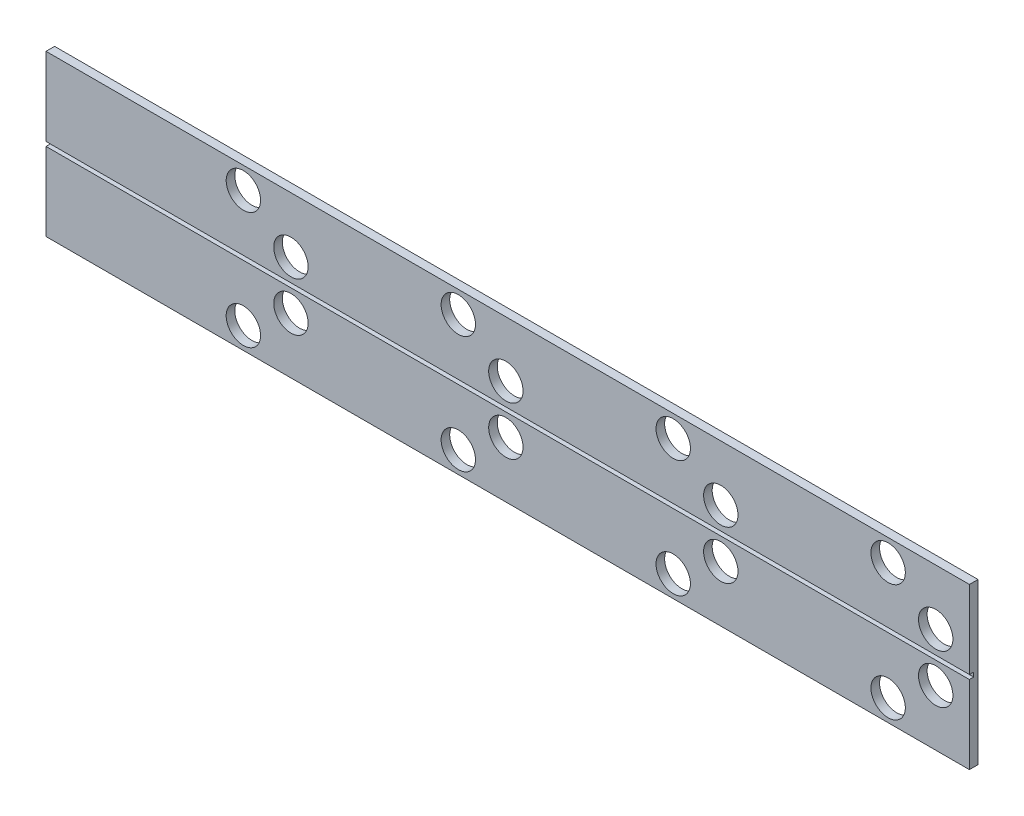
from build123d import *

# Parameters (mm, degrees)
SKIZZE1_W                       = 21.482125196
SKIZZE1_H                       = 3.731950896
AUFSATZ_LINEAR_AUSTRAGEN1_DEPTH = 0.2
SKIZZE2_W                       = 21.482125196
SKIZZE2_H                       = 0.1
SCHNITT_LINEAR_AUSTRAGEN1_DEPTH = 0.1
SKIZZE3_R                       = 0.4
SCHNITT_LINEAR_AUSTRAGEN2_DEPTH = 1.2
LINEARES_MUSTER1_COUNT          = 4
LINEARES_MUSTER1_PITCH          = 5


with BuildPart() as part:
    # Skizze1 → Aufsatz-Linear austragen1 (new body)
    with BuildSketch(Plane.XY):
        Rectangle(SKIZZE1_W, SKIZZE1_H)
    extrude(amount=AUFSATZ_LINEAR_AUSTRAGEN1_DEPTH)

    # Skizze2 → Schnitt-Linear austragen1 (cut)
    with BuildSketch(Plane.XY.offset(0.2)):
        Rectangle(SKIZZE2_W, SKIZZE2_H)
    extrude(amount=-SCHNITT_LINEAR_AUSTRAGEN1_DEPTH, mode=Mode.SUBTRACT)

    # Skizze3 → Schnitt-Linear austragen2 (cut, through all)
    with BuildSketch(Plane.XY.offset(0.2)):
        with Locations((9.957181888, -0.562943668)):
            Circle(SKIZZE3_R)
        with Locations((8.850641756, -1.365185264)):
            Circle(SKIZZE3_R)
        with Locations((9.957181888, 0.571259967)):
            Circle(SKIZZE3_R)
        with Locations((8.850641756, 1.359669812)):
            Circle(SKIZZE3_R)
    schnitt_linear_austragen2 = extrude(amount=-SCHNITT_LINEAR_AUSTRAGEN2_DEPTH, mode=Mode.SUBTRACT)

    # Lineares Muster1: Schnitt-Linear austragen2 ×4
    with Locations(*[(-i * LINEARES_MUSTER1_PITCH, 0, 0) for i in range(1, LINEARES_MUSTER1_COUNT)]):
        add(schnitt_linear_austragen2, mode=Mode.SUBTRACT)


solid = part.part
